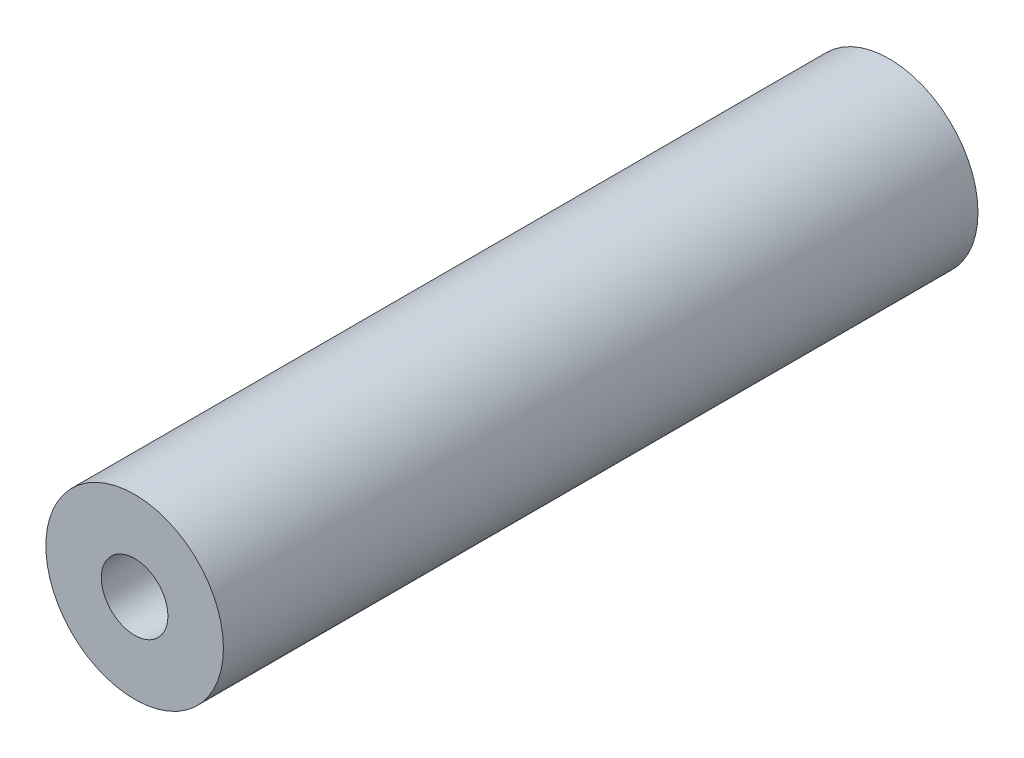
from build123d import *

# Parameters (mm, degrees)
SKETCH_1_R      = 4
SKETCH_1_R_2    = 1.5
EXTRUDE_1_DEPTH = 34


with BuildPart() as part:
    # Эскиз1 → Бобышка-Вытянуть1 (new body)
    with BuildSketch(Plane.XY):
        Circle(SKETCH_1_R)
        Circle(SKETCH_1_R_2, mode=Mode.SUBTRACT)
    extrude(amount=EXTRUDE_1_DEPTH)


solid = part.part
